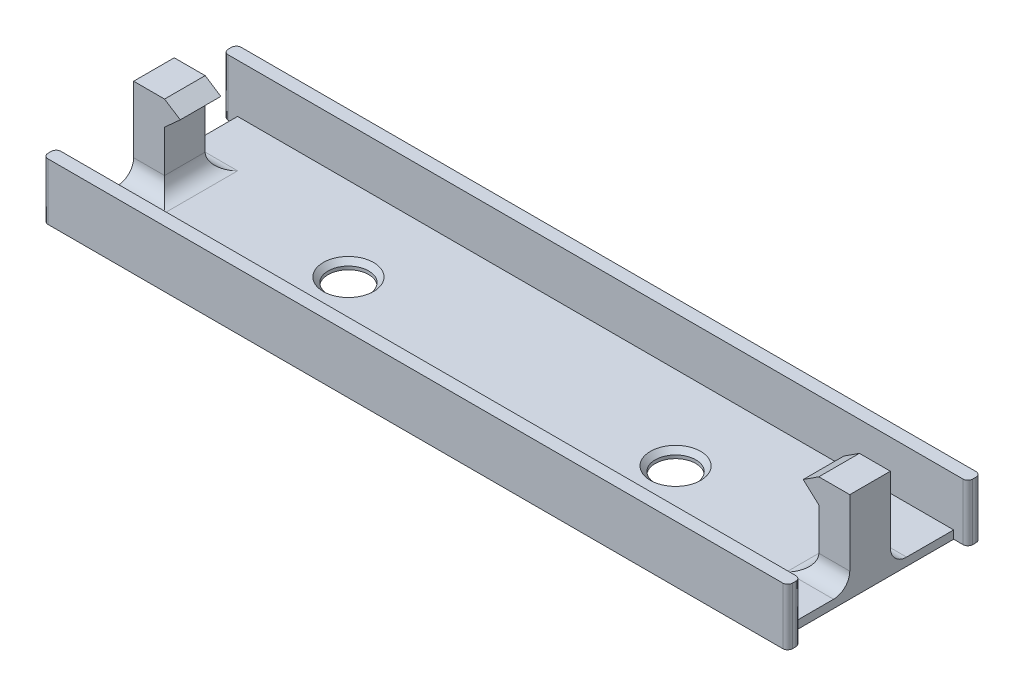
from build123d import *

# Parameters (mm, degrees)
SKETCH1_R           = 2.5
BOSS_EXTRUDE1_DEPTH = 1
SKETCH1_3_W         = 3.81
SKETCH1_3_H         = 5
BOSS_EXTRUDE2_DEPTH = 10.16
BOSS_EXTRUDE3_DEPTH = 6
BOSS_EXTRUDE4_DEPTH = 5
FILLET2_R           = 2
CHAMFER1_SIZE       = 0.6
FILLET3_R           = 0.6


with BuildPart() as part:
    # Sketch1 → Boss-Extrude1 (new body)
    with BuildSketch(Plane(origin=(0, 0, 0), x_dir=(1, 0, 0), z_dir=(0, 1, 0))):
        Polygon((-3.81, 0), (-5.56, 0), (-5.56, -1.6), (86.16, -1.6), (86.16, 0), (84.41, 0), (84.41, 20.6), (86.16, 20.6), (86.16, 22.2), (-5.56, 22.2), (-5.56, 20.6), (-3.81, 20.6), align=None)
        with Locations((20.15, 10.3)):
            Circle(SKETCH1_R, mode=Mode.SUBTRACT)
        with Locations((60.45, 10.3)):
            Circle(SKETCH1_R, mode=Mode.SUBTRACT)
    extrude(amount=-BOSS_EXTRUDE1_DEPTH)

    # Sketch1_3 → Boss-Extrude2 (add)
    with BuildSketch(Plane(origin=(0, 0, 0), x_dir=(1, 0, 0), z_dir=(0, 1, 0))):
        with Locations((-1.905, 10.3)):
            Rectangle(SKETCH1_3_W, SKETCH1_3_H)
        with Locations((82.505, 10.3)):
            Rectangle(SKETCH1_3_W, SKETCH1_3_H)
    extrude(amount=BOSS_EXTRUDE2_DEPTH)

    # Sketch1_4 → Boss-Extrude3 (add)
    with BuildSketch(Plane(origin=(0, 0, 0), x_dir=(1, 0, 0), z_dir=(0, 1, 0))):
        Polygon((80.6, 0), (0, 0), (-3.81, 0), (-5.56, 0), (-5.56, -1.6), (86.16, -1.6), (86.16, 0), (84.41, 0), align=None)
        Polygon((-3.81, 20.6), (0, 20.6), (80.6, 20.6), (84.41, 20.6), (86.16, 20.6), (86.16, 22.2), (-5.56, 22.2), (-5.56, 20.6), align=None)
    extrude(amount=BOSS_EXTRUDE3_DEPTH)

    # Sketch2 → Boss-Extrude4 (add)
    with BuildSketch(Plane.XY.offset(-7.8)):
        Polygon((0, 10.16), (1.927427041, 8.905), (0, 7.16), align=None)
    boss_extrude4 = extrude(amount=-BOSS_EXTRUDE4_DEPTH)

    # Mirror1: Boss-Extrude4 across plane
    add(boss_extrude4.mirror(Plane(origin=(40.3, 0, 0), x_dir=(0, 0, 1), z_dir=(1, 0, 0))))

    # Fillet2
    fillet2_edges = [part.edges().sort_by_distance(p)[0] for p in [
        (0, 0, -10.3),
        (-1.905, 0, -12.8),
        (-1.905, 0, -7.8),
        (82.505, 0, -7.8),
        (80.6, 0, -10.3),
        (82.505, 0, -12.8),
    ]]
    fillet(fillet2_edges, radius=FILLET2_R)

    # Chamfer1
    chamfer1_edges = [part.edges().sort_by_distance(p)[0] for p in [
        (17.65, 0, -10.3),
        (57.95, 0, -10.3),
    ]]
    chamfer(chamfer1_edges, length=CHAMFER1_SIZE)

    # Fillet3
    fillet3_edges = [part.edges().sort_by_distance(p)[0] for p in [
        (-5.56, 2.5, -20.6),
        (-5.56, 2.5, -22.2),
        (86.16, 2.5, -22.2),
        (86.16, 2.5, -20.6),
        (86.16, 2.5, 0),
        (86.16, 2.5, 1.6),
        (-5.56, 2.5, 1.6),
        (-5.56, 2.5, 0),
    ]]
    fillet(fillet3_edges, radius=FILLET3_R)


solid = part.part
